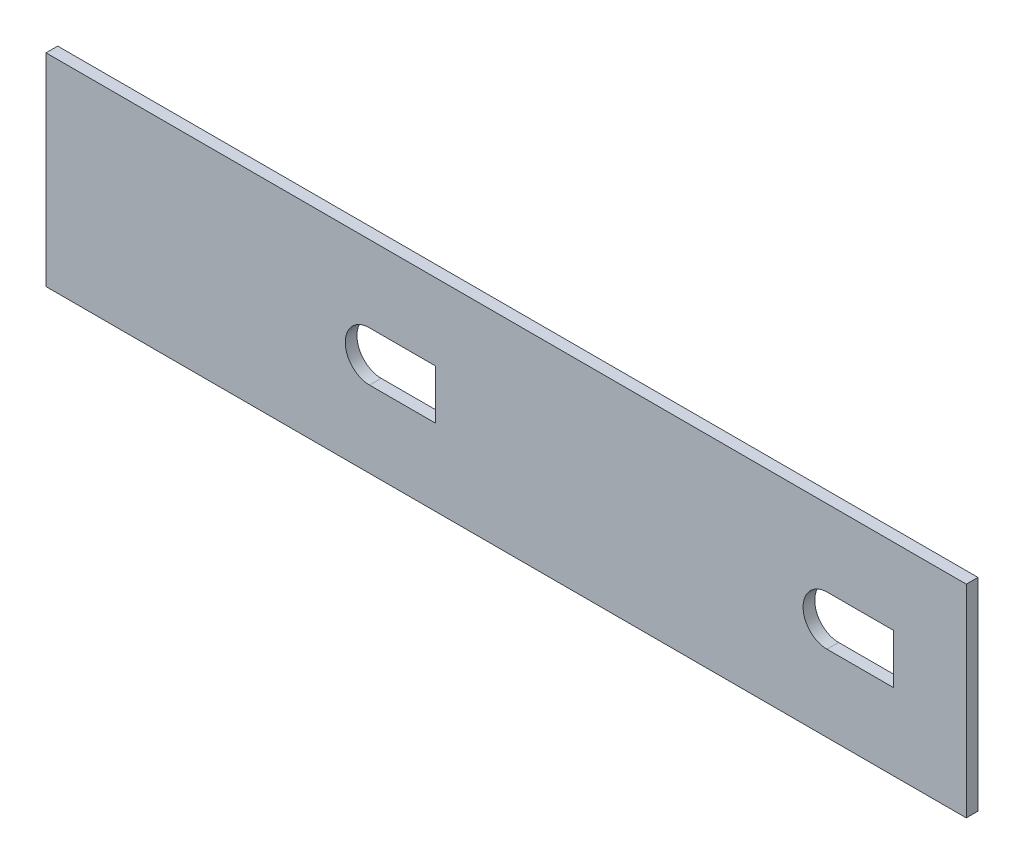
from build123d import *

# Parameters (mm, degrees)
SKETCH1_W           = 250
SKETCH1_H           = 55
BOSS_EXTRUDE1_DEPTH = 3.175


with BuildPart() as part:
    # Sketch1 → Boss-Extrude1 (new body)
    with BuildSketch(Plane.XY):
        with Locations((-241.58829827, -18.367364772)):
            Rectangle(SKETCH1_W, SKETCH1_H)
        with BuildLine():
            Line((-278.807431502, -11.635308713), (-260.807431502, -11.635308713))
            Line((-260.807431502, -11.635308713), (-260.807431502, -25.094140403))
            Line((-260.807431502, -25.094140403), (-278.708074604, -25.094140403))
            add(Edge.make_bspline(
                [(-278.807431502, -11.635308713), (-278.842567637, -11.635308713), (-278.877724877, -11.635597737), (-279.131916675, -11.639782512), (-279.34983121, -11.654506754), (-279.783435066, -11.706373741), (-280.000022761, -11.743764607), (-280.637043124, -11.888179154), (-281.046210232, -12.026893167), (-281.834248732, -12.387198003), (-282.214784616, -12.611112168), (-282.91286176, -13.122553874), (-283.23487643, -13.411547156), (-283.824414261, -14.056624874), (-284.084709523, -14.405325127), (-284.420910809, -14.959373126), (-284.524173104, -15.149599512), (-284.712815972, -15.541311056), (-284.798455074, -15.743725981), (-285.023266518, -16.356140938), (-285.132324707, -16.77404955), (-285.270965185, -17.628621863), (-285.299780117, -18.068728441), (-285.276335696, -18.934229846), (-285.225127225, -19.363108441), (-285.086887053, -20.000402626), (-285.030151101, -20.212732347), (-284.897978299, -20.627014671), (-284.822460465, -20.829775079), (-284.568196741, -21.425185334), (-284.362007249, -21.805088054), (-283.873373823, -22.529474489), (-283.596617119, -22.864951248), (-283.139203055, -23.322938066), (-282.979382751, -23.468376569), (-282.6446555, -23.744423912), (-282.468681353, -23.875710362), (-281.925950724, -24.240109672), (-281.545469248, -24.444161396), (-280.747183384, -24.774500883), (-280.324174276, -24.901275116), (-279.505292308, -25.056948004), (-279.108516523, -25.094140403), (-278.708074604, -25.094140403)],
                knots=[0.997490672, 0.997490672, 0.997490672, 0.997490672, 1, 1, 1.015625, 1.015625, 1.03125, 1.03125, 1.0625, 1.0625, 1.09375, 1.09375, 1.125, 1.125, 1.15625, 1.15625, 1.171875, 1.171875, 1.1875, 1.1875, 1.21875, 1.21875, 1.25, 1.25, 1.28125, 1.28125, 1.296875, 1.296875, 1.3125, 1.3125, 1.34375, 1.34375, 1.375, 1.375, 1.390625, 1.390625, 1.40625, 1.40625, 1.4375, 1.4375, 1.46875, 1.46875, 1.497597951, 1.497597951, 1.497597951, 1.497597951], degree=3))
        make_face(mode=Mode.SUBTRACT)
        with BuildLine():
            Line((-154.360316654, -11.635298321), (-136.360316654, -11.635298321))
            Line((-136.360316654, -11.635298321), (-136.360316654, -25.09414087))
            Line((-136.360316654, -25.09414087), (-154.458489548, -25.09414087))
            add(Edge.make_bspline(
                [(-154.360316654, -11.635298321), (-154.761727997, -11.635298321), (-155.157386504, -11.672727127), (-155.759665345, -11.787140661), (-155.970243269, -11.838376709), (-156.387966493, -11.963181969), (-156.594872022, -12.036850346), (-157.196347851, -12.28608082), (-157.576755859, -12.490915834), (-158.117253538, -12.854781423), (-158.293226627, -12.986353957), (-158.628820603, -13.263982392), (-158.788816486, -13.410133743), (-159.246155666, -13.869889244), (-159.521251185, -14.204841131), (-160.009167015, -14.931608928), (-160.214692704, -15.312488329), (-160.467795081, -15.908929825), (-160.542897196, -16.111961519), (-160.674225623, -16.52661774), (-160.730530769, -16.739037016), (-160.867597895, -17.37656092), (-160.918148194, -17.805473824), (-160.940601815, -18.670806399), (-160.911402505, -19.110937169), (-160.772322277, -19.965020543), (-160.663242958, -20.382313943), (-160.438953589, -20.993295919), (-160.353444122, -21.195550415), (-160.164485449, -21.587994273), (-160.061148171, -21.778323473), (-159.725133032, -22.332012421), (-159.46672666, -22.678256324), (-158.877844125, -23.322799834), (-158.553373423, -23.613738751), (-158.031112315, -23.995810431), (-157.850620858, -24.114523058), (-157.476451569, -24.334149523), (-157.281538298, -24.435580841), (-156.686819382, -24.706814458), (-156.277513308, -24.844436489), (-155.433635452, -25.034586177), (-154.994831316, -25.08641844), (-154.527357053, -25.093865983), (-154.492916253, -25.09414087), (-154.458489548, -25.09414087)],
                knots=[0.002538772, 0.002538772, 0.002538772, 0.002538772, 0.03125, 0.03125, 0.046875, 0.046875, 0.0625, 0.0625, 0.09375, 0.09375, 0.109375, 0.109375, 0.125, 0.125, 0.15625, 0.15625, 0.1875, 0.1875, 0.203125, 0.203125, 0.21875, 0.21875, 0.25, 0.25, 0.28125, 0.28125, 0.3125, 0.3125, 0.328125, 0.328125, 0.34375, 0.34375, 0.375, 0.375, 0.40625, 0.40625, 0.421875, 0.421875, 0.4375, 0.4375, 0.46875, 0.46875, 0.5, 0.5, 0.502486526, 0.502486526, 0.502486526, 0.502486526], degree=3))
        make_face(mode=Mode.SUBTRACT)
    extrude(amount=BOSS_EXTRUDE1_DEPTH)


solid = part.part
